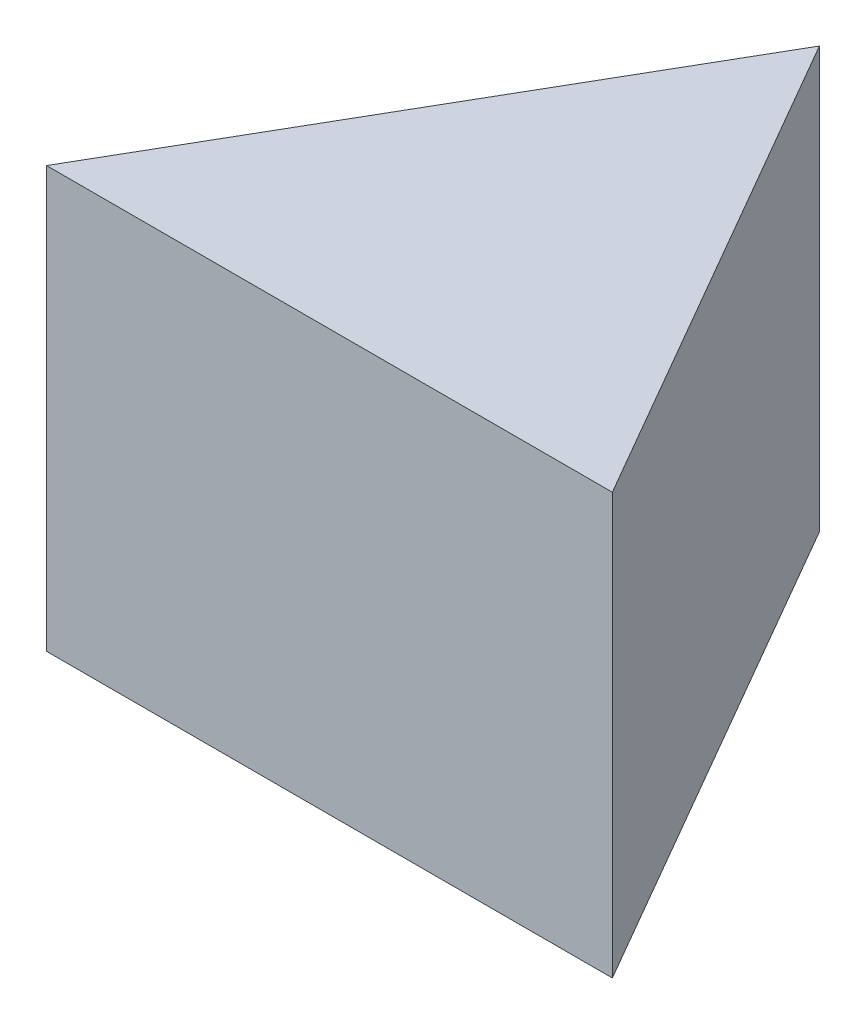
from build123d import *

# Parameters (mm, degrees)
EXTRUDE_1_DEPTH = 29


with BuildPart() as part:
    # 草圖1 → 填料-伸長1 (new body)
    with BuildSketch(Plane(origin=(0, 0, 0), x_dir=(1, 0, 0), z_dir=(0, 1, 0))):
        Polygon((0, 0), (39, 0), (19.5, 33.774990748), align=None)
    extrude(amount=EXTRUDE_1_DEPTH)


solid = part.part
